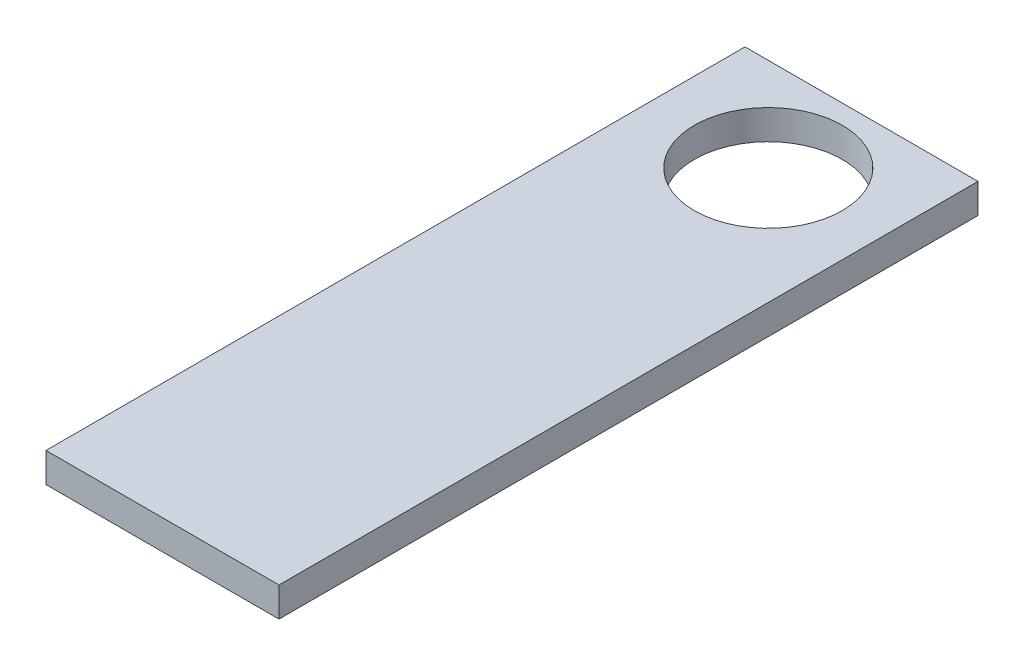
from build123d import *

# Parameters (mm, degrees)
SKETCH1_W           = 10
SKETCH1_H           = 30
SKETCH1_R           = 3.175
BOSS_EXTRUDE1_DEPTH = 1.27


with BuildPart() as part:
    # Sketch1 → Boss-Extrude1 (new body)
    with BuildSketch(Plane(origin=(0, 0, 0), x_dir=(1, 0, 0), z_dir=(0, 1, 0))):
        with Locations((5, -15)):
            Rectangle(SKETCH1_W, SKETCH1_H)
        with Locations((5, -4)):
            Circle(SKETCH1_R, mode=Mode.SUBTRACT)
    extrude(amount=BOSS_EXTRUDE1_DEPTH)


solid = part.part
